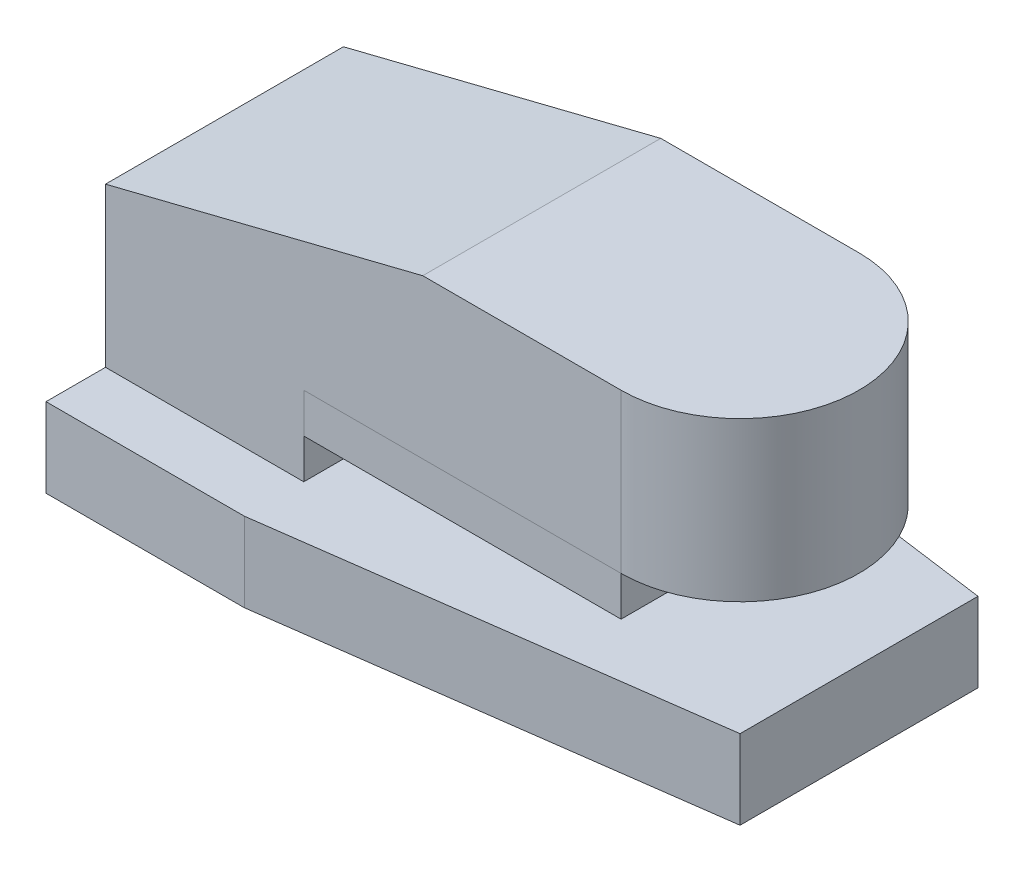
from build123d import *

# Parameters (mm, degrees)
EXTRUDE1_DEPTH = 20
EXTRUDE2_DEPTH = 60
EXTRUDE8_DEPTH = 40
SKETCH4_W      = 80
SKETCH4_H      = 10
EXTRUDE9_DEPTH = 60


with BuildPart() as part:
    # Sketch1 → Extrude1 (new body)
    with BuildSketch(Plane(origin=(0, 0, 0), x_dir=(1, 0, 0), z_dir=(0, 1, 0))):
        Polygon((50, 0), (160, 15), (160, 75), (50, 90), (0, 90), (0, 0), align=None)
    extrude(amount=EXTRUDE1_DEPTH)


with BuildPart() as body_2:
    # Sketch2 → Extrude2 (new body)
    with BuildSketch(Plane.XY.offset(-15)):
        Polygon((0, 20), (0, 60), (80, 80), (160, 80), (160, 40), (50, 40), (50, 20), align=None)
    extrude(amount=-EXTRUDE2_DEPTH)

    # Sketch3 → Extrude8 (cut)
    with BuildSketch(Plane(origin=(0, 80, 0), x_dir=(1, 0, 0), z_dir=(0, 1, 0))):
        with BuildLine():
            Line((160, 15), (160, 45))
            ThreePointArc((160, 45), (151.213203436, 23.786796564), (130, 15))
            Line((130, 15), (160, 15))
        make_face()
        with BuildLine():
            Line((160, 75), (130, 75))
            ThreePointArc((130, 75), (151.213203436, 66.213203436), (160, 45))
            Line((160, 45), (160, 75))
        make_face()
    extrude(amount=-EXTRUDE8_DEPTH, mode=Mode.SUBTRACT)


with BuildPart() as body_3:
    # Sketch4 → Extrude9 (new body)
    with BuildSketch(Plane.XY.offset(-15)):
        with Locations((90, 35)):
            Rectangle(SKETCH4_W, SKETCH4_H)
    extrude(amount=-EXTRUDE9_DEPTH)


solid = Compound([part.part, body_2.part, body_3.part])
